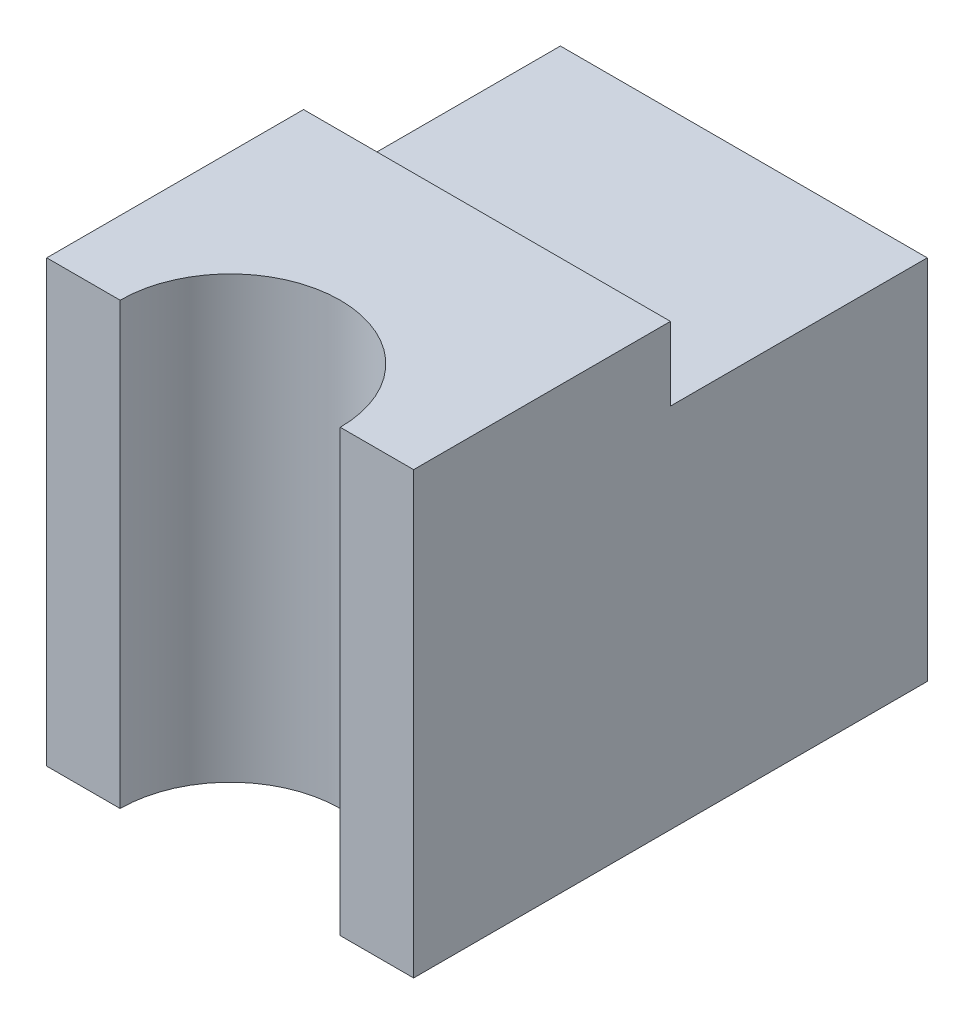
from build123d import *

# Parameters (mm, degrees)
SKETCH1_W           = 0.5
SKETCH1_H           = 0.7
BOSS_EXTRUDE1_DEPTH = 0.6
CUT_EXTRUDE1_REACH  = 2.6
SKETCH2_R           = 0.15
SKETCH3_W           = 0.5
SKETCH3_H           = 0.35
CUT_EXTRUDE2_DEPTH  = 0.1


with BuildPart() as part:
    # Sketch1 → Boss-Extrude1 (new body)
    with BuildSketch(Plane(origin=(0, 0, 0), x_dir=(1, 0, 0), z_dir=(0, 1, 0))):
        with Locations((0.25, 0.35)):
            Rectangle(SKETCH1_W, SKETCH1_H)
    extrude(amount=BOSS_EXTRUDE1_DEPTH)

    # Sketch2 → Cut-Extrude1 (cut, up to next)
    with BuildSketch(Plane(origin=(0, 0.6, 0), x_dir=(1, 0, 0), z_dir=(0, 1, 0)), mode=Mode.PRIVATE) as cut_extrude1_sk1:
        with Locations((0.25, 0)):
            Circle(SKETCH2_R)
    cut_extrude1_tool1 = extrude(cut_extrude1_sk1.sketch, amount=-CUT_EXTRUDE1_REACH, mode=Mode.PRIVATE) & part.part
    add(cut_extrude1_tool1.solids().sort_by_distance((0.25, 0.6, 0))[0], mode=Mode.SUBTRACT)

    # Sketch3 → Cut-Extrude2 (cut)
    with BuildSketch(Plane(origin=(0, 0.6, 0), x_dir=(1, 0, 0), z_dir=(0, 1, 0))):
        with Locations((0.25, 0.525)):
            Rectangle(SKETCH3_W, SKETCH3_H)
    extrude(amount=-CUT_EXTRUDE2_DEPTH, mode=Mode.SUBTRACT)


solid = part.part
